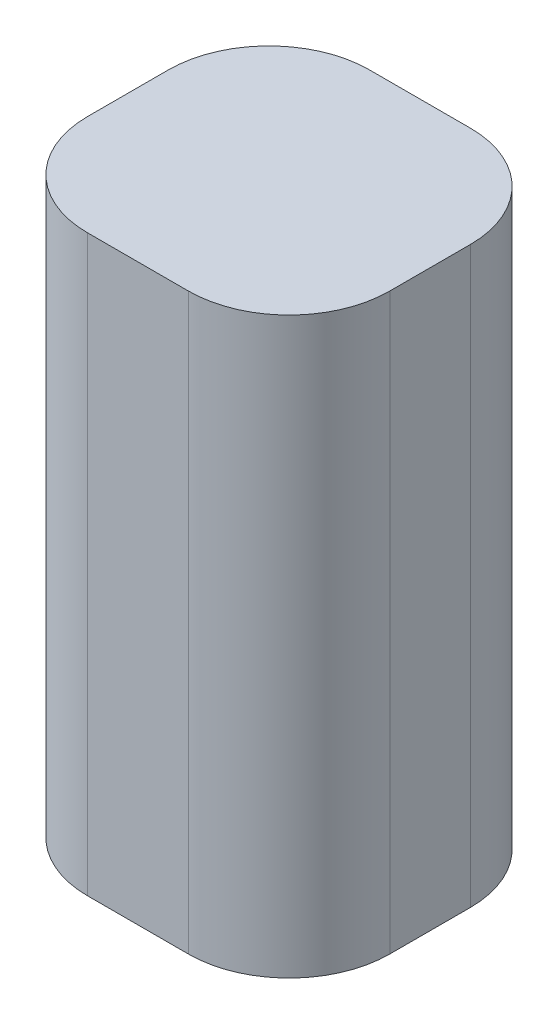
from build123d import *

# Parameters (mm, degrees)
SKETCH1_W           = 30
SKETCH1_H           = 57
BOSS_EXTRUDE1_DEPTH = 28
FILLET1_R           = 10


with BuildPart() as part:
    # Sketch1 → Boss-Extrude1 (new body)
    with BuildSketch(Plane.XY):
        Rectangle(SKETCH1_W, SKETCH1_H)
    extrude(amount=BOSS_EXTRUDE1_DEPTH)

    # Fillet1
    fillet1_edges = [part.edges().sort_by_distance(p)[0] for p in [
        (-15, 0, 28),
        (15, 0, 28),
        (-15, 0, 0),
        (15, 0, 0),
    ]]
    fillet(fillet1_edges, radius=FILLET1_R)


solid = part.part
